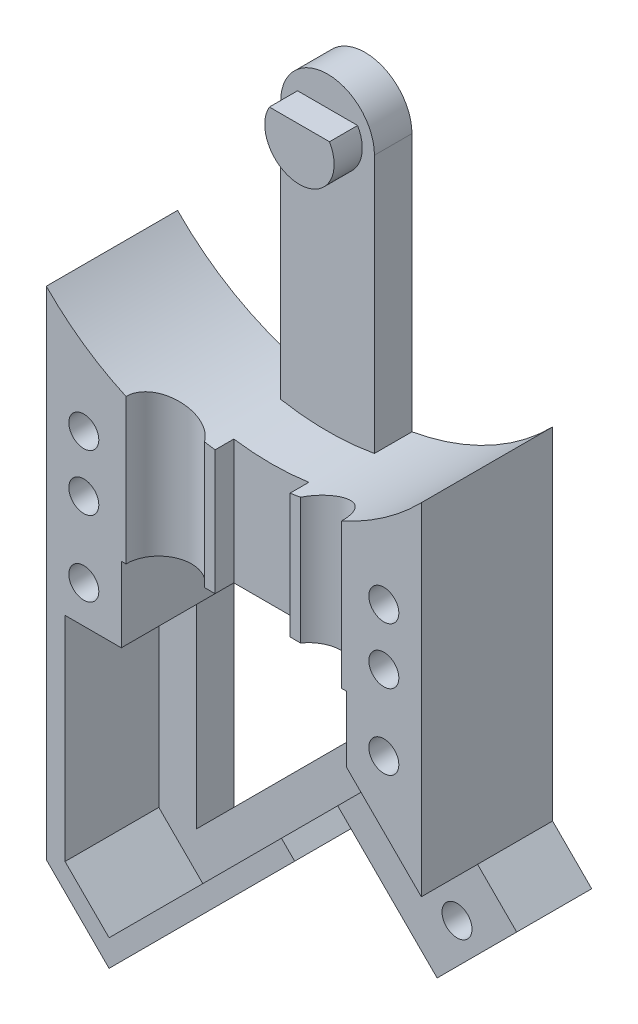
from build123d import *

# Parameters (mm, degrees)
BOSS_EXTRUDE1_DEPTH        = 7
BOSS_EXTRUDE2_DEPTH        = 2
BOSS_EXTRUDE3_DEPTH        = 2
BOSS_EXTRUDE4_START        = 2
BOSS_EXTRUDE4_DEPTH        = 1.5
WIRE_START                 = -3
SKETCH3_R                  = 1.75
WIRE_AND_TUBE_CANALS_DEPTH = 8.5
SKETCH5_R                  = 0.8
SKETCH5_R_2                = 0.799999999
SCREW_HOLES_DEPTH          = 8.0000001
CUT_EXTRUDE1_START         = 4
CUT_EXTRUDE1_DEPTH         = 3


with BuildPart() as part:
    # Sketch1 → Boss-Extrude1 (new body)
    with BuildSketch(Plane.XY):
        with BuildLine():
            Line((13.246912191, -20.732193563), (3.347417254, -30.6316885))
            Line((3.347417254, -30.6316885), (0, -27.284271246))
            Line((0, -27.284271246), (0, -0.797958973))
            ThreePointArc((0, -0.797958973), (9.999999999, -5), (19.999999998, -0.797958971))
            Line((19.999999998, -0.797958971), (19.999999998, -19))
            Line((19.999999998, -19), (22.085746954, -21.085746956))
            Line((22.085746954, -21.085746956), (17.843106269, -25.328387641))
            Line((17.843106269, -25.328387641), (13.246912191, -20.732193563))
        make_face()
        Polygon((1, -15.5), (1, -26.870057685), (3.347417253, -29.217474938), (15.999999998, -16.564892192), (15.999999998, -11.5), (4, -11.5), (4, -15.5), align=None, mode=Mode.SUBTRACT)
    extrude(amount=BOSS_EXTRUDE1_DEPTH)

    # Sketch6 → Boss-Extrude2 (add)
    with BuildSketch(Plane.XY):
        Polygon((1, -11.5), (3, -11.5), (3, -26.87005769), (17, -12.87005769), (17, -11.500000008), (19, -11.500000008), (19, -18.000000005), (17.843106267, -16.843106272), (14.307572361, -20.378640178), (13.246912189, -19.317980006), (3.347417253, -29.217474943), (1, -26.87005769), align=None)
    extrude(amount=BOSS_EXTRUDE2_DEPTH)

    # Sketch8 → Boss-Extrude3 (add)
    with BuildSketch(Plane.XY):
        with BuildLine():
            Line((10, -11.5), (12.5, -11.5))
            Line((12.5, -11.5), (12.5, 9))
            ThreePointArc((12.5, 9), (10, 11.5), (7.5, 9))
            Line((7.5, 9), (7.5, -11.5))
            Line((7.5, -11.5), (10, -11.5))
        make_face()
    extrude(amount=BOSS_EXTRUDE3_DEPTH)

    # Sketch9 → Boss-Extrude4 (add)
    with BuildSketch(Plane.XY.offset(BOSS_EXTRUDE4_START)):
        with BuildLine():
            Line((8.397853003, 9.925), (11.602146997, 9.925))
            ThreePointArc((11.602146997, 9.925), (10, 7.15), (8.397853003, 9.925))
        make_face()
    extrude(amount=BOSS_EXTRUDE4_DEPTH)

    # Sketch3 → Wire and Tube Canals (cut)
    with BuildSketch(Plane(origin=(0, 0, 0), x_dir=(1, 0, 0), z_dir=(0, 1, 0)).offset(WIRE_START)):
        with Locations((6, -7)):
            Circle(SKETCH3_R)
        with Locations((14, -7)):
            Circle(SKETCH3_R)
        Polygon((6, -6), (8, -6), (8, -5), (12, -5), (12, -6), (14, -6), (14, -7), (6, -7), align=None)
    extrude(amount=-WIRE_AND_TUBE_CANALS_DEPTH, mode=Mode.SUBTRACT)

    # Sketch5 → Screw Holes (cut, through all)
    with BuildSketch(Plane.XY):
        with Locations((2, -6.5)):
            Circle(SKETCH5_R)
        with Locations((2, -9.5)):
            Circle(SKETCH5_R)
        with Locations((18, -9.5)):
            Circle(SKETCH5_R)
        with Locations((18, -6.5)):
            Circle(SKETCH5_R)
        with Locations((18.90376644, -22.146407127)):
            Circle(SKETCH5_R_2)
        with Locations((16.782446096, -20.025086783)):
            Circle(SKETCH5_R_2)
        with Locations((2, -13.5)):
            Circle(SKETCH5_R)
        with Locations((18, -13.5)):
            Circle(SKETCH5_R)
    extrude(amount=SCREW_HOLES_DEPTH, mode=Mode.SUBTRACT)

    # Sketch10 → Cut-Extrude1 (cut)
    with BuildSketch(Plane.XY.offset(CUT_EXTRUDE1_START)):
        Polygon((17.843106269, -25.328387641), (22.085746954, -21.085746956), (15.721785923, -14.721785925), (11.479145238, -18.96442661), align=None)
    extrude(amount=CUT_EXTRUDE1_DEPTH, mode=Mode.SUBTRACT)


solid = part.part
